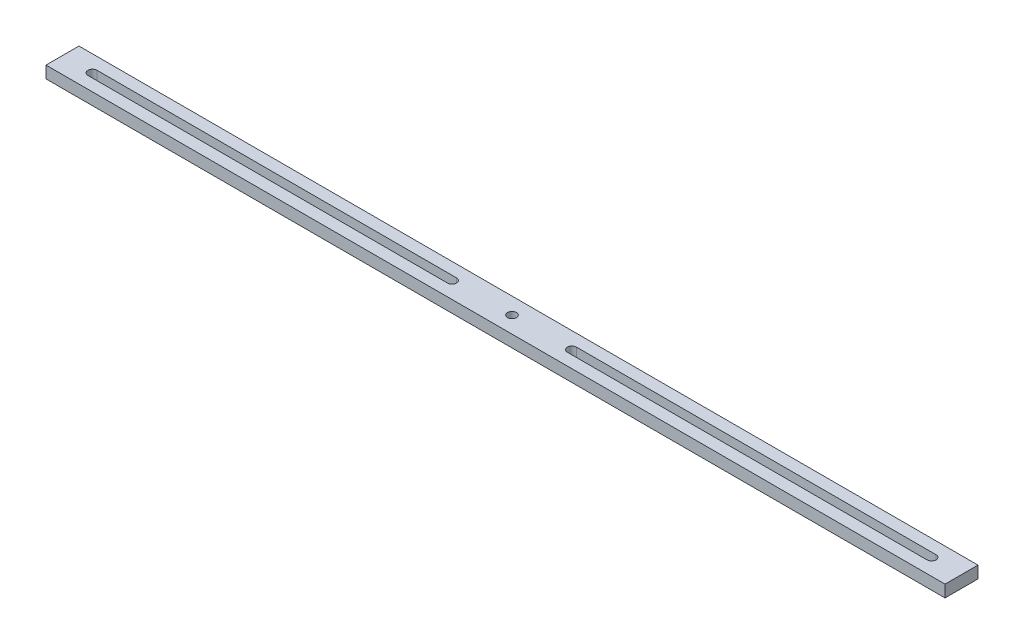
from build123d import *

# Parameters (mm, degrees)
SKETCH1_W           = 300
SKETCH1_H           = 11
SKETCH1_R           = 1.5
BOSS_EXTRUDE2_DEPTH = 4


with BuildPart() as part:
    # Sketch1 → Boss-Extrude2 (new body)
    with BuildSketch(Plane(origin=(0, 0, 0), x_dir=(1, 0, 0), z_dir=(0, 1, 0))):
        Rectangle(SKETCH1_W, SKETCH1_H)
        Circle(SKETCH1_R, mode=Mode.SUBTRACT)
        with BuildLine():
            Line((20, 1.5), (140, 1.5))
            ThreePointArc((140, 1.5), (141.5, 0), (140, -1.5))
            Line((140, -1.5), (20, -1.5))
            ThreePointArc((20, -1.5), (18.5, 0), (20, 1.5))
        make_face(mode=Mode.SUBTRACT)
        with BuildLine():
            Line((-20, -1.5), (-140, -1.5))
            ThreePointArc((-140, -1.5), (-141.5, 0), (-140, 1.5))
            Line((-140, 1.5), (-20, 1.5))
            ThreePointArc((-20, 1.5), (-18.5, 0), (-20, -1.5))
        make_face(mode=Mode.SUBTRACT)
    extrude(amount=BOSS_EXTRUDE2_DEPTH)


solid = part.part
